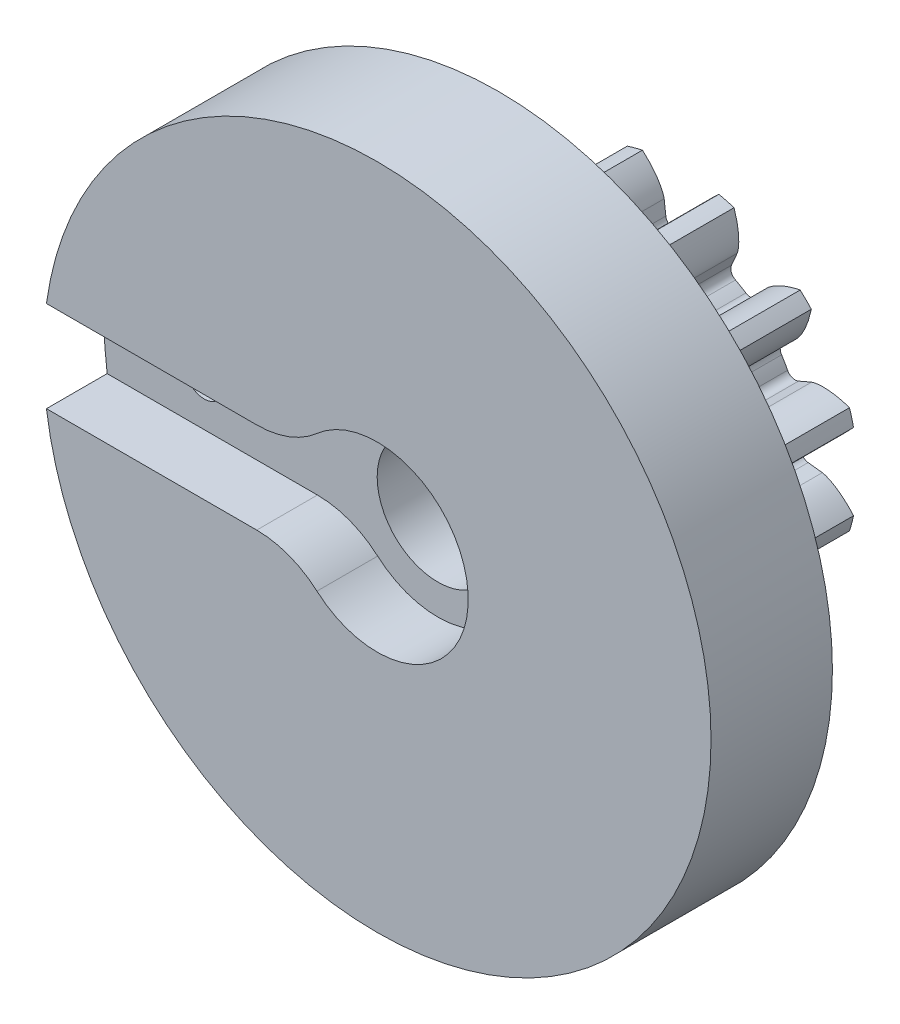
from build123d import *

# Parameters (mm, degrees)
SKETCH3_R                = 7.408333333
BOSS_EXTRUDE1_DEPTH      = 7.62
CUT_EXTRUDE1_START       = -8.62
CUT_EXTRUDE1_DEPTH       = 9.62
FILLET1_R                = 0.355076163
CIRPATTERN1_COUNT        = 12
FILLET1_OF_CIRPATTERN1_R = 0.355076163
SCALE1_SCALE             = 2
SKETCH10_R               = 27.94
BOSS_EXTRUDE4_DEPTH      = 10.16
SKETCH11_R               = 5.08
CUT_EXTRUDE5_DEPTH       = 26.4
CUT_EXTRUDE6_DEPTH       = 5.08
SKETCH13_R               = 1.5875
CUT_EXTRUDE12_DEPTH      = 21.3200001
SKETCH16_R               = 2.74955
CUT_EXTRUDE13_DEPTH      = 3.81


with BuildPart() as part:
    # Sketch3 → Boss-Extrude1 (new body)
    with BuildSketch(Plane.XY):
        Circle(SKETCH3_R)
    extrude(amount=-BOSS_EXTRUDE1_DEPTH)

    # Sketch4 → Cut-Extrude1 (cut)
    with BuildSketch(Plane.XY.offset(CUT_EXTRUDE1_START)):
        with BuildLine():
            Line((4.993301754, 0.581811335), (5.926950078, 0.690598508))
            add(Edge.make_bspline(
                [(5.926950078, 0.690598508), (5.929318191, 0.690911872), (5.935944647, 0.691904892), (5.948407954, 0.694232443), (5.96863478, 0.69866684), (5.994230847, 0.70524939), (6.027084964, 0.714822349), (6.065467787, 0.727462413), (6.107282331, 0.74277265), (6.152345854, 0.760950457), (6.196898763, 0.780422108), (6.240942495, 0.801081108), (6.284441008, 0.822769247), (6.336662498, 0.8503395), (6.398612769, 0.885198626), (6.469984516, 0.92853373), (6.54965538, 0.980716028), (6.629400976, 1.037091207), (6.706647925, 1.095172788), (6.78320647, 1.156800213), (6.856219389, 1.218511327), (6.930432721, 1.285554849), (6.998115798, 1.348944008), (7.07205666, 1.423150182), (7.131183599, 1.483972917), (7.190627906, 1.549410219), (7.219315962, 1.581641114), (7.233873511, 1.598273068)],
                knots=[0, 0, 0, 0, 0, 0.005376749, 0.015083688, 0.02853182, 0.046610139, 0.064854849, 0.092110525, 0.119476176, 0.146842496, 0.174208854, 0.201574956, 0.228941013, 0.256307345, 0.307035032, 0.361767352, 0.416499661, 0.471231937, 0.525964282, 0.580696615, 0.635428982, 0.690161387, 0.744893688, 0.799626082, 0.854358408, 0.909090915, 0.909090915, 0.909090915, 0.909090915, 0.909090915], degree=4))
            ThreePointArc((7.233873511, 1.598273068), (7.408333333, 0), (7.233873511, -1.598273068))
            add(Edge.make_bspline(
                [(5.926950078, -0.690598508), (5.929318191, -0.690911872), (5.935944647, -0.691904892), (5.948407954, -0.694232443), (5.96863478, -0.69866684), (5.994230847, -0.70524939), (6.027084964, -0.714822349), (6.065467787, -0.727462413), (6.107282331, -0.74277265), (6.152345854, -0.760950457), (6.196898763, -0.780422108), (6.240942495, -0.801081108), (6.284441008, -0.822769247), (6.336662498, -0.8503395), (6.398612769, -0.885198626), (6.469984516, -0.92853373), (6.54965538, -0.980716028), (6.629400976, -1.037091207), (6.706647925, -1.095172788), (6.78320647, -1.156800213), (6.856219389, -1.218511327), (6.930432721, -1.285554849), (6.998115798, -1.348944008), (7.07205666, -1.423150182), (7.131183599, -1.483972917), (7.190627906, -1.549410219), (7.219315962, -1.581641114), (7.233873511, -1.598273068)],
                knots=[0, 0, 0, 0, 0, 0.005376749, 0.015083688, 0.02853182, 0.046610139, 0.064854849, 0.092110525, 0.119476176, 0.146842496, 0.174208854, 0.201574956, 0.228941013, 0.256307345, 0.307035032, 0.361767352, 0.416499661, 0.471231937, 0.525964282, 0.580696615, 0.635428982, 0.690161387, 0.744893688, 0.799626082, 0.854358408, 0.909090915, 0.909090915, 0.909090915, 0.909090915, 0.909090915], degree=4))
            Line((5.926950078, -0.690598508), (4.993301754, -0.581811335))
            ThreePointArc((4.993301754, -0.581811335), (5.027083333, 0), (4.993301754, 0.581811335))
        make_face()
    cut_extrude1 = extrude(amount=CUT_EXTRUDE1_DEPTH, mode=Mode.SUBTRACT)

    # Fillet1
    fillet1_edges = [part.edges().sort_by_distance(p)[0] for p in [
        (4.993301754, -0.581811335, -3.81),
        (4.993301754, 0.581811335, -3.81),
    ]]
    fillet(fillet1_edges, radius=FILLET1_R)

    # CirPattern1: Cut-Extrude1 ×12 about axis
    cirpattern1_axis = Axis((0, 0, 6.35), (0, 0, -1))
    for i in range(1, CIRPATTERN1_COUNT):
        add(cut_extrude1.rotate(cirpattern1_axis, i * 360 / CIRPATTERN1_COUNT), mode=Mode.SUBTRACT)

    # Fillet1 of CirPattern1
    fillet1_of_cirpattern1_edges = [part.edges().sort_by_distance(p)[0] for p in [
        (4.0334205, -3.000514274, -3.81),
        (4.615231836, -1.99278748, -3.81),
        (1.99278748, -4.615231836, -3.81),
        (3.000514274, -4.0334205, -3.81),
        (-0.581811335, -4.993301754, -3.81),
        (0.581811335, -4.993301754, -3.81),
        (-3.000514274, -4.0334205, -3.81),
        (-1.99278748, -4.615231836, -3.81),
        (-4.615231836, -1.99278748, -3.81),
        (-4.0334205, -3.000514274, -3.81),
        (-4.993301754, 0.581811335, -3.81),
        (-4.993301754, -0.581811335, -3.81),
        (-4.0334205, 3.000514274, -3.81),
        (-4.615231836, 1.99278748, -3.81),
        (-1.99278748, 4.615231836, -3.81),
        (-3.000514274, 4.0334205, -3.81),
        (0.581811335, 4.993301754, -3.81),
        (-0.581811335, 4.993301754, -3.81),
        (3.000514274, 4.0334205, -3.81),
        (1.99278748, 4.615231836, -3.81),
        (4.615231836, 1.99278748, -3.81),
        (4.0334205, 3.000514274, -3.81),
    ]]
    fillet(fillet1_of_cirpattern1_edges, radius=FILLET1_OF_CIRPATTERN1_R)


with BuildPart() as part_1:
    # Scale1: scaled about (0, 0, 0)
    add(part.part.scale(SCALE1_SCALE))

    # Sketch10 → Boss-Extrude4 (add)
    with BuildSketch(Plane.XY):
        Circle(SKETCH10_R)
    extrude(amount=BOSS_EXTRUDE4_DEPTH)

    # Sketch11 → Cut-Extrude5 (cut, through all)
    with BuildSketch(Plane(origin=(0, 0, -15.24), x_dir=(-1, 0, 0), z_dir=(0, 0, -1))):
        Circle(SKETCH11_R)
    extrude(amount=-CUT_EXTRUDE5_DEPTH, mode=Mode.SUBTRACT)

    # Sketch12 → Cut-Extrude6 (cut)
    with BuildSketch(Plane.XY.offset(10.16)):
        with BuildLine():
            Line((-10.080312495, -3.81), (-28.438556916, -3.81))
            Line((-28.438556916, -3.81), (-28.438556916, 3.81))
            Line((-28.438556916, 3.81), (-10.080312495, 3.81))
            ThreePointArc((-10.080312495, 3.81), (-7.386235659, 4.302142678), (-5.040156248, 5.715))
            ThreePointArc((-5.040156248, 5.715), (7.62, 0), (-5.040156248, -5.715))
            ThreePointArc((-5.040156248, -5.715), (-7.386235659, -4.302142678), (-10.080312495, -3.81))
        make_face()
    extrude(amount=-CUT_EXTRUDE6_DEPTH, mode=Mode.SUBTRACT)

    # Sketch13 → Cut-Extrude12 (cut, through all)
    with BuildSketch(Plane.XY.offset(5.08)):
        with Locations((-19.558, 0)):
            Circle(SKETCH13_R)
    extrude(amount=-CUT_EXTRUDE12_DEPTH, mode=Mode.SUBTRACT)

    # Sketch16 → Cut-Extrude13 (cut)
    with BuildSketch(Plane(origin=(0, 0, 0), x_dir=(-1, 0, 0), z_dir=(0, 0, -1))):
        with Locations((19.558, 0)):
            Circle(SKETCH16_R)
    extrude(amount=-CUT_EXTRUDE13_DEPTH, mode=Mode.SUBTRACT)


solid = part_1.part
